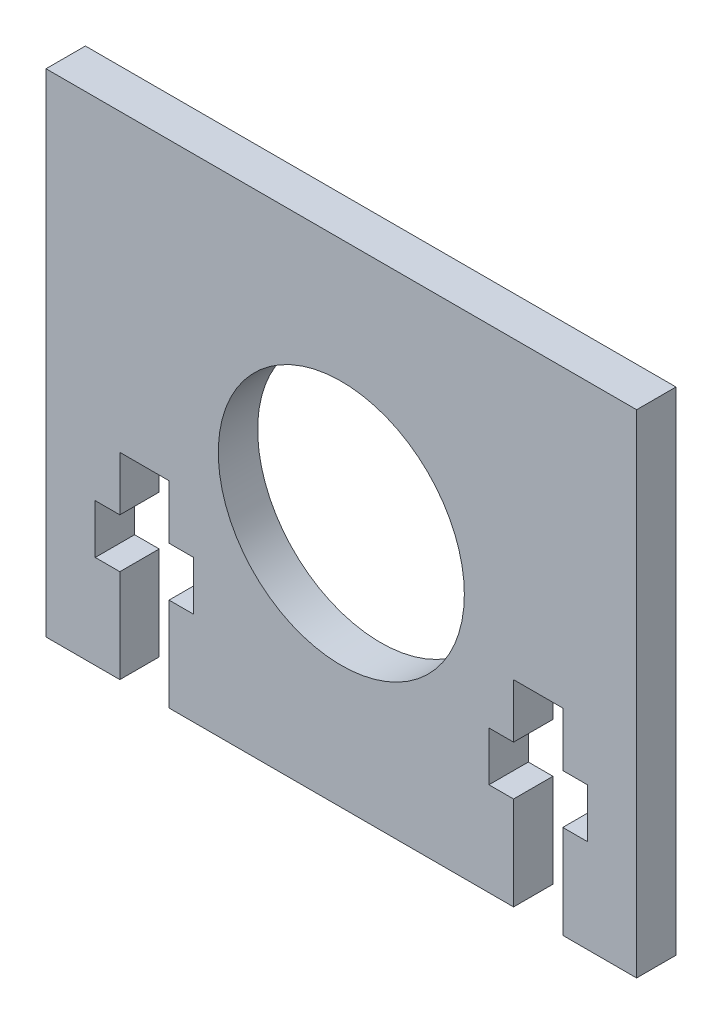
from build123d import *

# Parameters (mm, degrees)
SKETCH1_W           = 60
SKETCH1_H           = 50
SKETCH1_R           = 12.5
BOSS_EXTRUDE1_DEPTH = 4
CUT_EXTRUDE1_DEPTH  = 5


with BuildPart() as part:
    # Sketch1 → Boss-Extrude1 (new body)
    with BuildSketch(Plane.XY):
        Rectangle(SKETCH1_W, SKETCH1_H)
        Circle(SKETCH1_R, mode=Mode.SUBTRACT)
    extrude(amount=BOSS_EXTRUDE1_DEPTH)

    # Sketch2 → Cut-Extrude1 (cut, through all)
    with BuildSketch(Plane.XY.offset(4)):
        Polygon((-17.5, -5), (-22.5, -5), (-22.5, -10.5), (-25, -10.5), (-25, -15.5), (-22.5, -15.5), (-22.5, -25), (-17.5, -25), (-17.5, -15.5), (-15, -15.5), (-15, -10.5), (-17.5, -10.5), align=None)
        Polygon((22.5, -5), (17.5, -5), (17.5, -10.5), (15, -10.5), (15, -15.5), (17.5, -15.5), (17.5, -25), (22.5, -25), (22.5, -15.5), (25, -15.5), (25, -10.5), (22.5, -10.5), align=None)
    extrude(amount=-CUT_EXTRUDE1_DEPTH, mode=Mode.SUBTRACT)


solid = part.part
